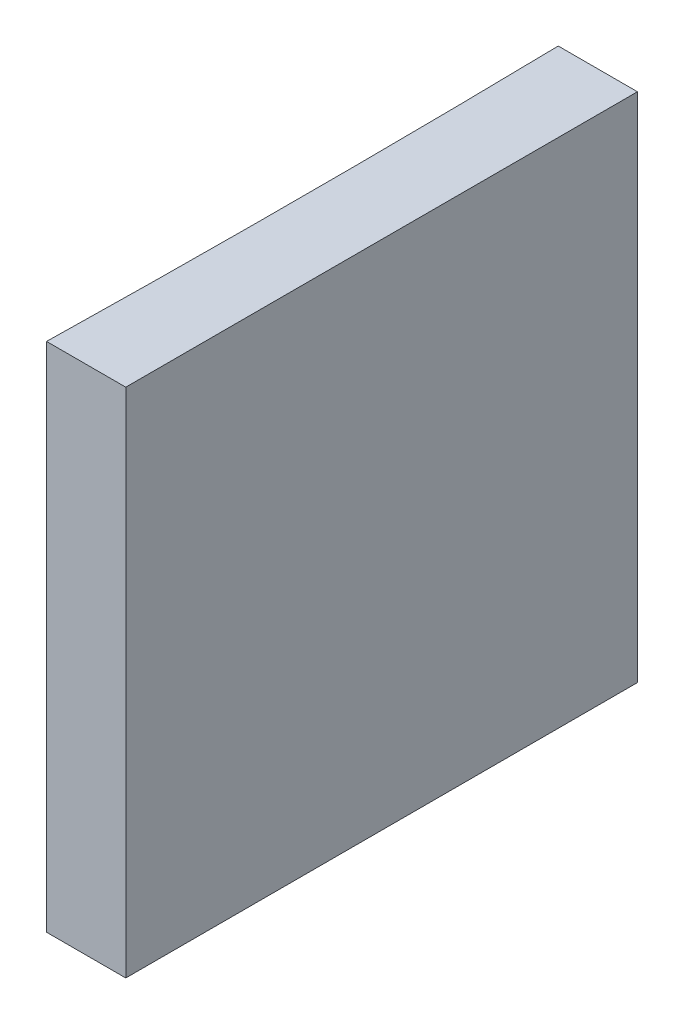
from build123d import *

# Parameters (mm, degrees)
EXTRUDE_1_DEPTH = 20


with BuildPart() as part:
    # 草图1 → 凸台-拉伸1 (new body)
    with BuildSketch(Plane(origin=(0, 0, 0), x_dir=(1, 0, 0), z_dir=(0, 1, 0))):
        with BuildLine():
            Line((0, 0), (0, -20))
            Line((0, -20), (-3.096758284, -20))
            ThreePointArc((-3.096758284, -20), (-3, -10), (-3.096758284, 0))
            Line((-3.096758284, 0), (0, 0))
        make_face()
    extrude(amount=EXTRUDE_1_DEPTH)


solid = part.part
